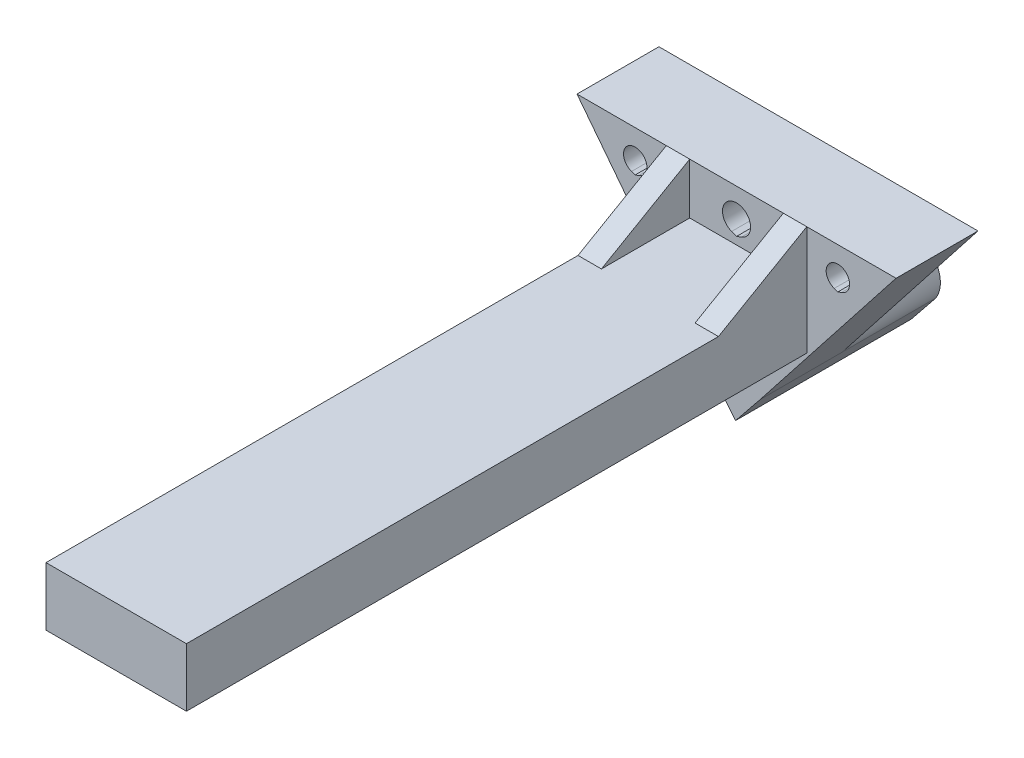
from build123d import *

# Parameters (mm, degrees)
SKETCH1_W            = 12
SKETCH1_H            = 60
BOSS_EXTRUDE1_DEPTH  = 1
SKETCH4_W            = 12
SKETCH4_H            = 60
BOSS_EXTRUDE5_DEPTH  = 4
SKETCH3_W            = 0.442585723
SKETCH3_H            = 46.400729484
SKETCH3_W_2          = 0.4
CUT_EXTRUDE1_DEPTH   = 3
SKETCH5_W            = 12
SKETCH5_H            = 5
BOSS_EXTRUDE6_DEPTH  = 7
BOSS_EXTRUDE11_DEPTH = 8
BOSS_EXTRUDE12_DEPTH = 2
BOSS_EXTRUDE13_DEPTH = 0.75
BOSS_EXTRUDE15_DEPTH = 2


with BuildPart() as part:
    # Sketch1 → Boss-Extrude1 (new body)
    with BuildSketch(Plane(origin=(0, 0, 0), x_dir=(1, 0, 0), z_dir=(0, 1, 0))):
        with Locations((-1.342029662, -10.461538462)):
            Rectangle(SKETCH1_W, SKETCH1_H)
    extrude(amount=BOSS_EXTRUDE1_DEPTH)

    # Sketch4 → Boss-Extrude5 (add)
    with BuildSketch(Plane(origin=(0, 0, 0), x_dir=(1, 0, 0), z_dir=(0, 1, 0))):
        with Locations((-1.342029662, -10.461538462)):
            Rectangle(SKETCH4_W, SKETCH4_H)
        Polygon((-2.096130055, -33.457130572), (-6.384615385, -37.75443168), (-6.384611455, -29.168649172), align=None, mode=Mode.SUBTRACT)
        Polygon((2.908277834, -38.461538462), (-5.677508603, -38.461538462), (-1.384615385, -34.168645243), align=None, mode=Mode.SUBTRACT)
        Polygon((-1.38975443, -32.749302861), (-5.677336591, -28.461186458), (-1.384615385, -24.168121227), (2.898997747, -28.451734358), align=None, mode=Mode.SUBTRACT)
        Polygon((-2.091498793, -23.461237818), (-6.384610808, -27.754427103), (-6.384606877, -19.168129734), align=None, mode=Mode.SUBTRACT)
        Polygon((-1.384401984, -22.754128282), (-5.676963509, -18.461572954), (-1.384618257, -14.16814285), (2.90844487, -18.461204162), align=None, mode=Mode.SUBTRACT)
        Polygon((-2.094846949, -13.457914458), (-6.38460623, -17.742175237), (-6.38460623, -9.168156991), align=None, mode=Mode.SUBTRACT)
        Polygon((3.615384615, -29.168645243), (3.615384615, -37.75443168), (-0.749170508, -33.533200366), align=None, mode=Mode.SUBTRACT)
        Polygon((3.615384615, -19.168465252), (3.615384615, -27.753907665), (-0.677336591, -23.461186458), align=None, mode=Mode.SUBTRACT)
        Polygon((3.615384615, -17.754251693), (-0.676897524, -13.461506969), (3.615384615, -9.169224829), align=None, mode=Mode.SUBTRACT)
        Polygon((-6.384597723, 0.832144172), (-2.091409836, -3.461043715), (-6.384601653, -7.753916614), align=None, mode=Mode.SUBTRACT)
        Polygon((2.908517821, -8.460971372), (-1.387204346, -12.751178894), (-5.677010576, -8.461229413), (-1.384615385, -4.167838166), align=None, mode=Mode.SUBTRACT)
        Polygon((-1.385221722, -2.75490806), (-5.679497842, 1.537745361), (-1.38541394, 5.831829263), (2.908210299, 1.538205024), align=None, mode=Mode.SUBTRACT)
        Polygon((-2.089578329, 6.535993652), (-6.3837953, 2.241776681), (-6.384597078, 2.240974904), (-6.384597078, 2.242578156), (-6.384593146, 10.83100847), align=None, mode=Mode.SUBTRACT)
        Polygon((-5.677832652, 11.538461538), (2.912889557, 11.538461538), (-1.382471548, 7.243100433), align=None, mode=Mode.SUBTRACT)
        Polygon((3.615384615, -7.755011267), (-0.677821818, -3.462040655), (3.615384615, 0.831165778), align=None, mode=Mode.SUBTRACT)
        Polygon((3.615384615, 2.245379341), (-0.678307159, 6.538936044), (3.615384615, 10.832627818), align=None, mode=Mode.SUBTRACT)
    extrude(amount=-BOSS_EXTRUDE5_DEPTH)

    # Sketch3 → Cut-Extrude1 (cut)
    with BuildSketch(Plane.XZ.offset(4)):
        with Locations((3.436677476, 13.26117372)):
            Rectangle(SKETCH3_W, SKETCH3_H)
        with Locations((-6.184615385, 13.26117372)):
            Rectangle(SKETCH3_W_2, SKETCH3_H)
    extrude(amount=-CUT_EXTRUDE1_DEPTH, mode=Mode.SUBTRACT)

    # Sketch5 → Boss-Extrude6 (add)
    with BuildSketch(Plane(origin=(0, 0, -19.538461538), x_dir=(-1, 0, 0), z_dir=(0, 0, -1))):
        Polygon((14.972848388, 5.355892869), (-12.288789064, 5.355892869), (-0.689767913, -9.409188123), (1.425918842, -12.033387248), (3.537352374, -9.415920613), align=None)
        with Locations((1.342029662, -1.5)):
            Rectangle(SKETCH5_W, SKETCH5_H, mode=Mode.SUBTRACT)
        with BuildLine():
            Line((-7.315384615, 1.857726092), (-7.622102723, 1.966121199))
            ThreePointArc((-7.622102723, 1.966121199), (-7.315384615, 3.917921599), (-7.008666508, 1.966121199))
            Line((-7.008666508, 1.966121199), (-7.315384615, 1.857726092))
        make_face(mode=Mode.SUBTRACT)
        with BuildLine():
            Line((1.342029662, 1.636661499), (0.921478569, 1.79402802))
            ThreePointArc((0.921478569, 1.79402802), (1.342029662, 4.117921599), (1.762580755, 1.79402802))
            Line((1.762580755, 1.79402802), (1.342029662, 1.636661499))
        make_face(mode=Mode.SUBTRACT)
        with BuildLine():
            Line((9.999443939, 1.857726092), (9.692725832, 1.966121199))
            ThreePointArc((9.692725832, 1.966121199), (9.999443939, 3.917921599), (10.306162047, 1.966121199))
            Line((10.306162047, 1.966121199), (9.999443939, 1.857726092))
        make_face(mode=Mode.SUBTRACT)
    extrude(amount=-BOSS_EXTRUDE6_DEPTH)

    # Sketch5_3 → Boss-Extrude11 (add)
    with BuildSketch(Plane(origin=(0, 0, -19.538461538), x_dir=(-1, 0, 0), z_dir=(0, 0, -1))):
        with BuildLine():
            ThreePointArc((3.537352374, -9.415920613), (1.429900561, -5.57732435), (-0.689767913, -9.409188123))
            Line((-0.689767913, -9.409188123), (1.425918842, -12.033387248))
            Line((1.425918842, -12.033387248), (3.537352374, -9.415920613))
        make_face()
    extrude(amount=BOSS_EXTRUDE11_DEPTH)

    # Sketch11 → Boss-Extrude12 (add)
    with BuildSketch(Plane.ZY.offset(7.342029662)):
        Polygon((-12.538461538, 5.355892869), (-4.993833778, 1), (-12.538461538, 1), align=None)
    extrude(amount=-BOSS_EXTRUDE12_DEPTH)

    # Sketch12 → Boss-Extrude13 (add, symmetric)
    with BuildSketch(Plane.ZY.offset(1.342029662)):
        Polygon((-13.859142787, 0.316720052), (-13.859142787, -4.418628297), (-13.859142787, -9.68323793), (-6.410996577, -3.888931374), (-6.410996577, 0.316720052), align=None)
    extrude(amount=BOSS_EXTRUDE13_DEPTH, both=True)

    # Sketch14 → Boss-Extrude15 (add)
    with BuildSketch(Plane(origin=(4.657970338, 0, 0), x_dir=(0, 0, -1), z_dir=(1, 0, 0))):
        Polygon((4.993833778, 1), (12.538461538, 5.355892869), (12.538461538, 1), align=None)
    extrude(amount=-BOSS_EXTRUDE15_DEPTH)


solid = part.part
